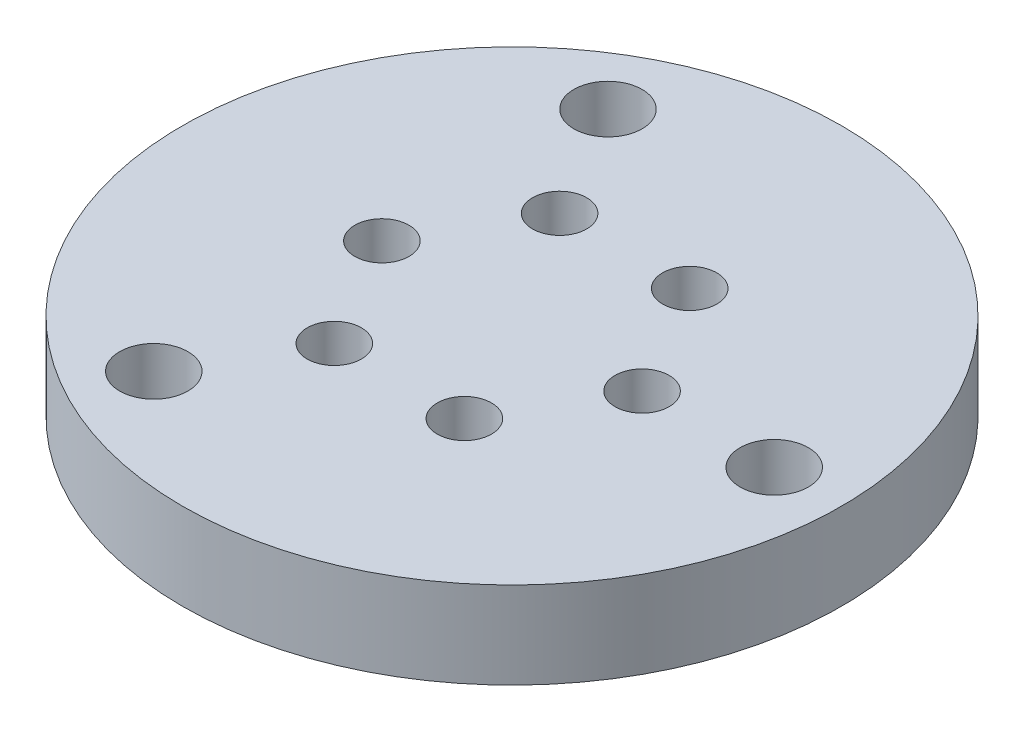
from build123d import *

# Parameters (mm, degrees)
SKETCH1_R                       = 24.13
SKETCH1_R_2                     = 2.5
BOSS_EXTRUDE1_DEPTH             = 6.35
F_5_32_0_15625_DIAMETER_HOLE1_D = 3.96875


with BuildPart() as part:
    # Sketch1 → Boss-Extrude1 (new body)
    with BuildSketch(Plane(origin=(0, 0, 0), x_dir=(1, 0, 0), z_dir=(0, 1, 0))):
        Circle(SKETCH1_R)
        with Locations((19.2, 0)):
            Circle(SKETCH1_R_2, mode=Mode.SUBTRACT)
        with Locations((-9.6, 16.627687753)):
            Circle(SKETCH1_R_2, mode=Mode.SUBTRACT)
        with Locations((-9.6, -16.627687753)):
            Circle(SKETCH1_R_2, mode=Mode.SUBTRACT)
    extrude(amount=BOSS_EXTRUDE1_DEPTH)

    # 5/32 (0.15625) Diameter Hole1 (through all)
    with Locations(Plane(origin=(0, 6.35, 0), x_dir=(1, 0, 0), z_dir=(0, 1, 0))):
        with Locations((4.7625, 8.248891971), (-4.7625, 8.248891971), (-9.525, 0), (-4.7625, -8.248891971), (4.7625, -8.248891971), (9.525, 0)):
            Hole(F_5_32_0_15625_DIAMETER_HOLE1_D / 2)


solid = part.part
